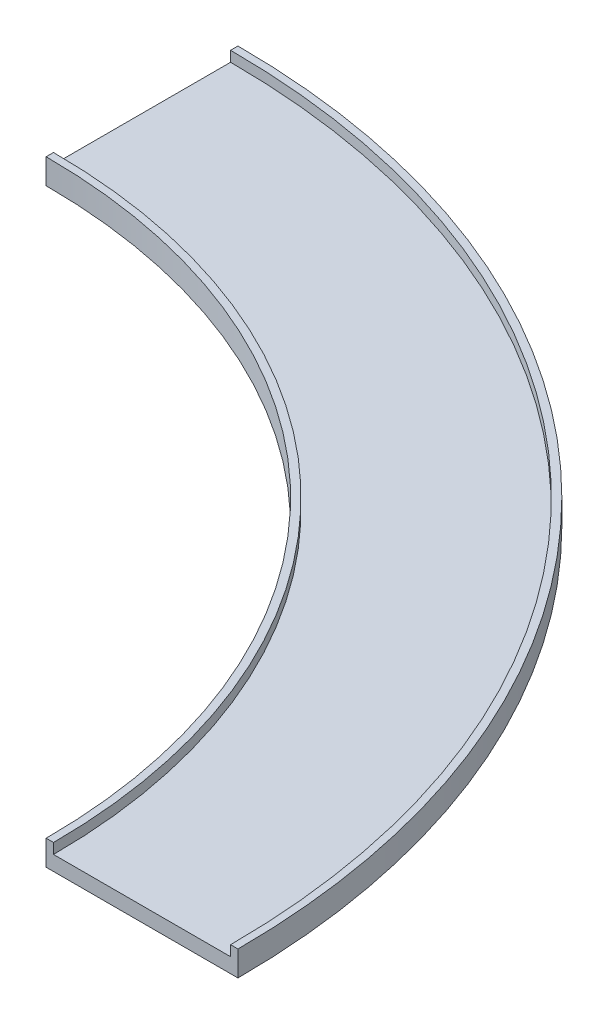
from build123d import *

# Parameters (mm, degrees)
REVOLVE3_ANGLE = 90


with BuildPart() as part:
    # Sketch1 → Revolve3 (revolve)
    with BuildSketch(Plane.XY):
        Polygon((0, 0), (25, 0), (25, -35.236081748), (625, -35.236081748), (625, 0), (650, 0), (650, -85.236081748), (0, -85.236081748), align=None)
    revolve(axis=Axis((-2000, 0, 0), (0, 1, 0)), revolution_arc=REVOLVE3_ANGLE)


solid = part.part
